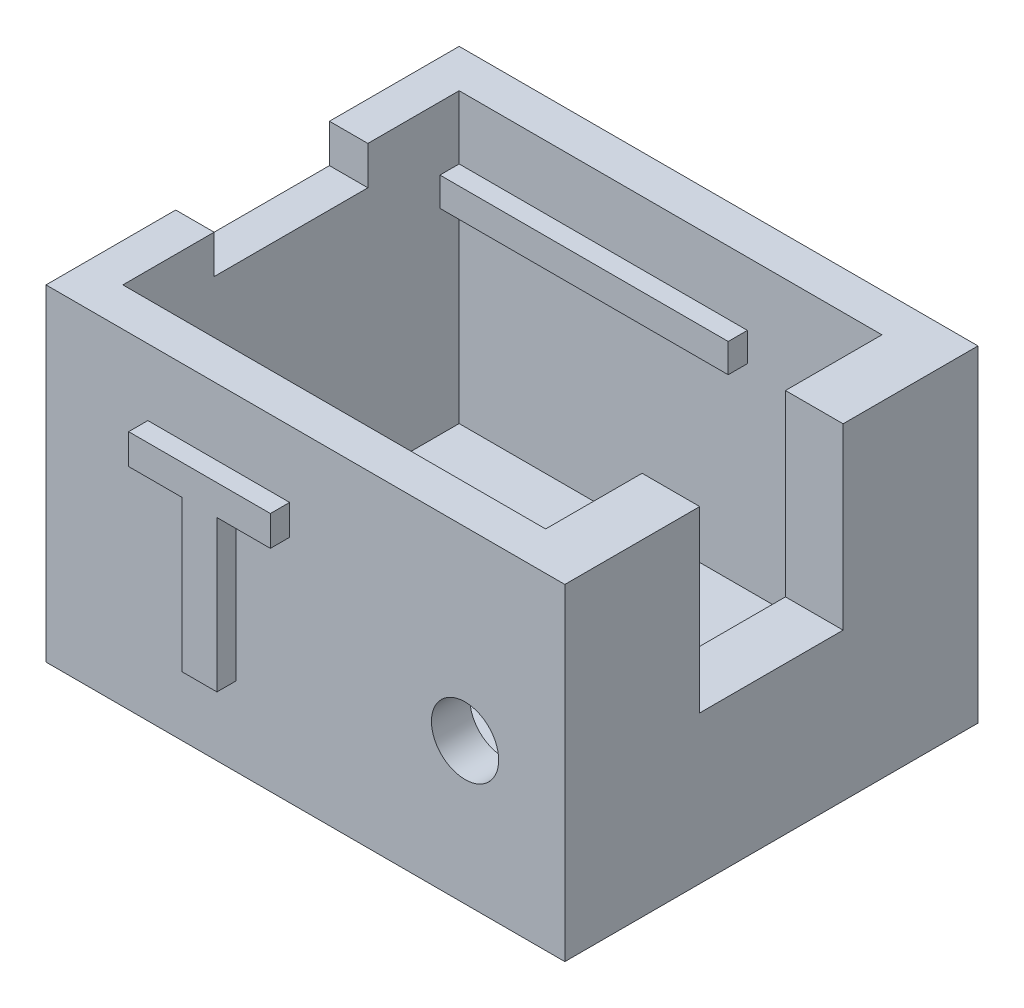
from build123d import *

# Parameters (mm, degrees)
SKETCH1_W           = 27
SKETCH1_H           = 21.5
BOSS_EXTRUDE1_DEPTH = 2
SKETCH2_W           = 27
SKETCH2_H           = 21.5
SKETCH2_W_2         = 22
SKETCH2_H_2         = 17.5
BOSS_EXTRUDE2_DEPTH = 15
SKETCH3_W           = 15
SKETCH3_H           = 1.5
BOSS_EXTRUDE3_DEPTH = 1
SKETCH4_W           = 15
SKETCH4_H           = 1
BOSS_EXTRUDE4_DEPTH = 1
SKETCH7_R           = 1.75
CUT_EXTRUDE2_DEPTH  = 2
SKETCH8_W           = 3
SKETCH8_H           = 7.46
CUT_EXTRUDE3_DEPTH  = 9.3
BOSS_EXTRUDE5_DEPTH = 1
BOSS_EXTRUDE6_DEPTH = 1
SKETCH11_W          = 2
SKETCH11_H          = 8
CUT_EXTRUDE4_DEPTH  = 2


with BuildPart() as part:
    # Sketch1 → Boss-Extrude1 (new body)
    with BuildSketch(Plane(origin=(0, 0, 0), x_dir=(1, 0, 0), z_dir=(0, 1, 0))):
        with Locations((7.695979899, -3.494974874)):
            Rectangle(SKETCH1_W, SKETCH1_H)
    extrude(amount=BOSS_EXTRUDE1_DEPTH)

    # Sketch2 → Boss-Extrude2 (add)
    with BuildSketch(Plane(origin=(0, 2, 0), x_dir=(1, 0, 0), z_dir=(0, 1, 0))):
        with Locations((7.695979899, -3.494974874)):
            Rectangle(SKETCH2_W, SKETCH2_H)
        with Locations((7.195979899, -3.494974874)):
            Rectangle(SKETCH2_W_2, SKETCH2_H_2, mode=Mode.SUBTRACT)
    extrude(amount=BOSS_EXTRUDE2_DEPTH)

    # Sketch3 → Boss-Extrude3 (add)
    with BuildSketch(Plane.XY.offset(-5.255025126)):
        with Locations((3.695979899, 12.95)):
            Rectangle(SKETCH3_W, SKETCH3_H)
    extrude(amount=BOSS_EXTRUDE3_DEPTH)

    # Sketch4 → Boss-Extrude4 (add)
    with BuildSketch(Plane(origin=(0, 0, 12.244974874), x_dir=(-1, 0, 0), z_dir=(0, 0, -1))):
        with Locations((-3.695979899, 13.2)):
            Rectangle(SKETCH4_W, SKETCH4_H)
    extrude(amount=BOSS_EXTRUDE4_DEPTH)

    # Sketch7 → Cut-Extrude2 (cut)
    with BuildSketch(Plane.XY.offset(14.244974874)):
        with Locations((16.00290807, 7.361856015)):
            Circle(SKETCH7_R)
    extrude(amount=-CUT_EXTRUDE2_DEPTH, mode=Mode.SUBTRACT)

    # Sketch8 → Cut-Extrude3 (cut)
    with BuildSketch(Plane(origin=(0, 17, 0), x_dir=(1, 0, 0), z_dir=(0, 1, 0))):
        with Locations((19.695979899, -3.494974874)):
            Rectangle(SKETCH8_W, SKETCH8_H)
    extrude(amount=-CUT_EXTRUDE3_DEPTH, mode=Mode.SUBTRACT)

    # Sketch9 → Boss-Extrude5 (add)
    with BuildSketch(Plane.ZY.offset(5.804020101)):
        Polygon((-4.61402787, 3.994511949), (-4.61402787, 13.240459214), (-2.756318514, 13.240459214), (0.957248046, 7.16539771), (0.957248046, 13.240459214), (2.735314828, 13.240459214), (2.735314828, 3.994511949), (0.822040884, 3.994511949), (-2.835961089, 9.976965808), (-2.835961089, 3.994511949), align=None)
        with BuildLine():
            Line((4.631919395, 13.240459214), (6.409986177, 13.240459214))
            Line((6.409986177, 13.240459214), (6.409986177, 8.222977014))
            add(Edge.make_bspline(
                [(6.409986177, 8.222977014), (6.410664977, 8.127899938), (6.411960871, 7.946388772), (6.412852908, 7.687065219), (6.417789545, 7.454232779), (6.428495129, 7.247516275), (6.435842667, 7.067021131), (6.449486246, 6.912714219), (6.46309676, 6.784655632), (6.476329448, 6.708485325), (6.48222014, 6.674577192)],
                knots=[0, 0, 0, 0, 0.000285238, 0.000544546, 0.000777983, 0.00098378, 0.001165528, 0.001319802, 0.001448457, 0.00155168, 0.00155168, 0.00155168, 0.00155168], degree=3))
            add(Edge.make_bspline(
                [(6.48222014, 6.674577192), (6.506506, 6.583165819), (6.554327924, 6.403165284), (6.686142733, 6.157109332), (6.860268235, 5.940226506), (7.037882666, 5.785554138), (7.198548601, 5.676088514), (7.335021148, 5.609466156), (7.47981763, 5.548735594), (7.63599912, 5.502137547), (7.801889384, 5.46136258), (7.979492203, 5.437786208), (8.167308711, 5.419691929), (8.296044968, 5.417890479), (8.362155331, 5.416965374)],
                knots=[0, 0, 0, 0, 0.000282968, 0.000557199, 0.000829969, 0.001113451, 0.001260368, 0.00141195, 0.001568103, 0.001730967, 0.001900335, 0.002080022, 0.002267831, 0.002466089, 0.002466089, 0.002466089, 0.002466089], degree=3))
            add(Edge.make_bspline(
                [(8.362155331, 5.416965374), (8.42885346, 5.41817507), (8.558713354, 5.420530322), (8.74690251, 5.434556672), (8.922479775, 5.46101956), (9.085337742, 5.495717516), (9.23633657, 5.539569917), (9.374271612, 5.595092211), (9.498925505, 5.661908259), (9.645391949, 5.762616554), (9.802989652, 5.904683185), (9.954657319, 6.097840917), (10.063204683, 6.311066042), (10.114117997, 6.505756529), (10.140285731, 6.675384373), (10.156228521, 6.823814626), (10.170809009, 6.99178617), (10.184049207, 7.178838934), (10.193103805, 7.385113322), (10.198001278, 7.611131016), (10.201855616, 7.856855971), (10.202738101, 8.027264527), (10.203195312, 8.115552146)],
                knots=[0, 0, 0, 0, 0.00020011, 0.000389609, 0.000565632, 0.000732377, 0.000888849, 0.001036743, 0.001177616, 0.001312213, 0.001569242, 0.001810797, 0.00204521, 0.002281568, 0.00241098, 0.002560087, 0.002729283, 0.0029168, 0.003122597, 0.003348628, 0.003594992, 0.003859856, 0.003859856, 0.003859856, 0.003859856], degree=3))
            Line((10.203195312, 8.115552146), (10.203195312, 13.240459214))
            Line((10.203195312, 13.240459214), (11.981262093, 13.240459214))
            Line((11.981262093, 13.240459214), (11.981262093, 8.404487998))
            add(Edge.make_bspline(
                [(11.981262093, 8.404487998), (11.981034195, 8.271131655), (11.980596294, 8.014891106), (11.973759084, 7.646224887), (11.959227844, 7.307989087), (11.947059184, 6.999603918), (11.923586339, 6.721856103), (11.89901035, 6.47457295), (11.867350881, 6.257797674), (11.822204183, 6.011401071), (11.746332221, 5.734959937), (11.624052705, 5.42959525), (11.467775809, 5.151778752), (11.278124263, 4.900444487), (11.056190615, 4.674593522), (10.798651876, 4.475113752), (10.508156306, 4.299580065), (10.241950666, 4.173184842), (10.009853453, 4.08807444), (9.820814155, 4.030475534), (9.61849876, 3.982507696), (9.403144549, 3.94444095), (9.174658985, 3.912345052), (8.932959111, 3.890910251), (8.678410596, 3.877533423), (8.50478883, 3.876502272), (8.415867765, 3.875974163)],
                knots=[0, 0, 0, 0, 0.000400069, 0.000768722, 0.001106063, 0.001415727, 0.001694438, 0.001942135, 0.002161113, 0.002351461, 0.002693408, 0.003019119, 0.003335923, 0.003646716, 0.003961047, 0.004283013, 0.004621309, 0.004977577, 0.005165094, 0.005362546, 0.005570094, 0.005788436, 0.006018417, 0.006262065, 0.00651614, 0.006782876, 0.006782876, 0.006782876, 0.006782876], degree=3))
            add(Edge.make_bspline(
                [(8.415867765, 3.875974163), (8.309052797, 3.877339536), (8.10213628, 3.879984467), (7.801779753, 3.891783276), (7.521923904, 3.916136469), (7.261689478, 3.94905209), (7.02118392, 3.991366197), (6.799798809, 4.041952447), (6.59930158, 4.105886329), (6.360493291, 4.19719937), (6.094301616, 4.336877712), (5.804540716, 4.523207483), (5.550180475, 4.733513713), (5.333455831, 4.965741446), (5.152282464, 5.211729672), (5.005020527, 5.466155478), (4.887009657, 5.724778163), (4.837698017, 5.904525991), (4.813430379, 5.992984925)],
                knots=[0, 0, 0, 0, 0.000320471, 0.000620799, 0.000901509, 0.001162945, 0.001407464, 0.001633889, 0.0018436, 0.002038279, 0.002400265, 0.002742918, 0.003070414, 0.003387527, 0.003693514, 0.003984821, 0.004268412, 0.004543212, 0.004543212, 0.004543212, 0.004543212], degree=3))
            add(Edge.make_bspline(
                [(4.813430379, 5.992984925), (4.79857773, 6.062627668), (4.767293301, 6.209317553), (4.731762874, 6.442525714), (4.699348655, 6.699326958), (4.677209321, 6.980025037), (4.65622326, 7.283729346), (4.64115601, 7.611012524), (4.634960344, 7.961800253), (4.632953465, 8.203837094), (4.631919395, 8.328549729)],
                knots=[0, 0, 0, 0, 0.000213585, 0.000449878, 0.000707407, 0.000989962, 0.001294397, 0.001620713, 0.0019727, 0.002346853, 0.002346853, 0.002346853, 0.002346853], degree=3))
            Line((4.631919395, 8.328549729), (4.631919395, 13.240459214))
        make_face()
    extrude(amount=BOSS_EXTRUDE5_DEPTH)

    # Sketch10 → Boss-Extrude6 (add)
    with BuildSketch(Plane.XY.offset(14.244974874)):
        Polygon((2.278412827, 4.103597224), (2.278412827, 11.963582575), (-0.502812759, 11.963582575), (-0.502812759, 13.535579645), (6.873481186, 13.535579645), (6.873481186, 11.963582575), (4.0922556, 11.963582575), (4.0922556, 4.103597224), align=None)
    extrude(amount=BOSS_EXTRUDE6_DEPTH)

    # Sketch11 → Cut-Extrude4 (cut)
    with BuildSketch(Plane(origin=(0, 17, 0), x_dir=(1, 0, 0), z_dir=(0, 1, 0))):
        with Locations((-4.804020101, -3.494974874)):
            Rectangle(SKETCH11_W, SKETCH11_H)
    extrude(amount=-CUT_EXTRUDE4_DEPTH, mode=Mode.SUBTRACT)


solid = part.part
